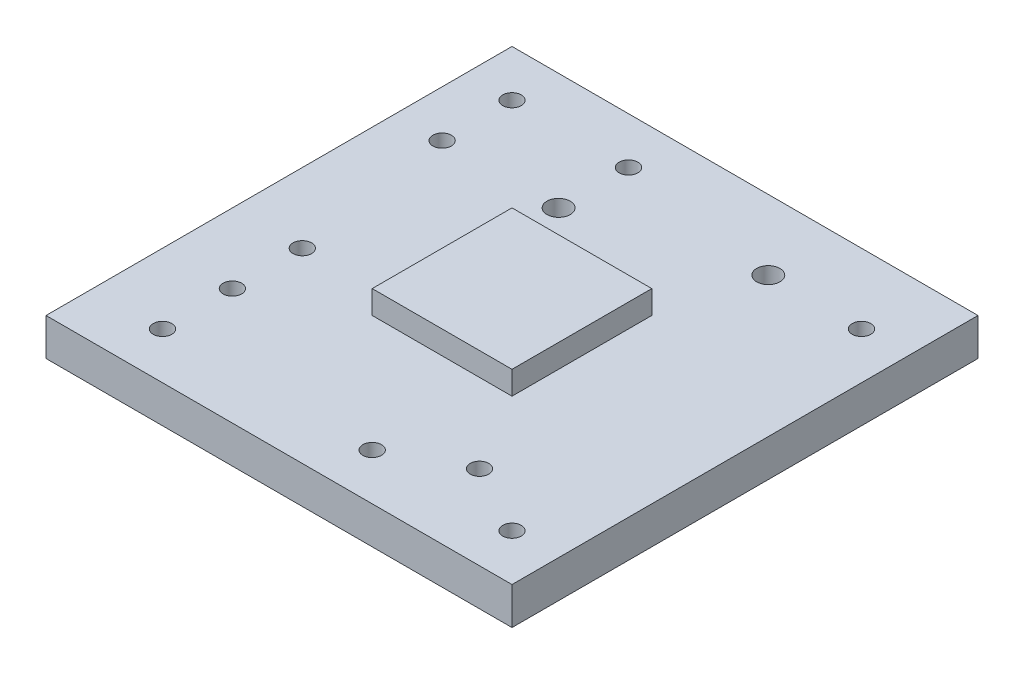
from build123d import *

# Parameters (mm, degrees)
SKETCH1_W           = 100
SKETCH1_H           = 100
BOSS_EXTRUDE1_DEPTH = 8
SKETCH2_W           = 30
SKETCH2_H           = 30
BOSS_EXTRUDE2_DEPTH = 5
SKETCH3_R           = 2
SKETCH3_R_2         = 2.5
CUT_EXTRUDE1_DEPTH  = 19
SKETCH4_R           = 2
SKETCH4_R_2         = 2.5
CUT_EXTRUDE2_DEPTH  = 19
SKETCH5_R           = 2
CUT_EXTRUDE3_DEPTH  = 19
SKETCH6_R           = 2
CUT_EXTRUDE4_DEPTH  = 19


with BuildPart() as part:
    # Sketch1 → Boss-Extrude1 (new body)
    with BuildSketch(Plane(origin=(0, 0, 0), x_dir=(1, 0, 0), z_dir=(0, 1, 0))):
        with Locations((50, 50)):
            Rectangle(SKETCH1_W, SKETCH1_H)
    extrude(amount=BOSS_EXTRUDE1_DEPTH)

    # Sketch2 → Boss-Extrude2 (add)
    with BuildSketch(Plane(origin=(0, 8, 0), x_dir=(1, 0, 0), z_dir=(0, 1, 0))):
        with Locations((50, 50)):
            Rectangle(SKETCH2_W, SKETCH2_H)
    extrude(amount=BOSS_EXTRUDE2_DEPTH)

    # Sketch3 → Cut-Extrude1 (cut)
    with BuildSketch(Plane(origin=(0, 8, 0), x_dir=(1, 0, 0), z_dir=(0, 1, 0))):
        with Locations((10, 90)):
            Circle(SKETCH3_R)
        with Locations((35, 90)):
            Circle(SKETCH3_R)
        with Locations((10, 75)):
            Circle(SKETCH3_R)
        with Locations((35, 75)):
            Circle(SKETCH3_R_2)
    extrude(amount=-CUT_EXTRUDE1_DEPTH, mode=Mode.SUBTRACT)

    # Sketch4 → Cut-Extrude2 (cut)
    with BuildSketch(Plane(origin=(0, 8, 0), x_dir=(1, 0, 0), z_dir=(0, 1, 0))):
        with Locations((90, 85)):
            Circle(SKETCH4_R)
        with Locations((70, 85)):
            Circle(SKETCH4_R_2)
    extrude(amount=-CUT_EXTRUDE2_DEPTH, mode=Mode.SUBTRACT)

    # Sketch5 → Cut-Extrude3 (cut)
    with BuildSketch(Plane(origin=(0, 8, 0), x_dir=(1, 0, 0), z_dir=(0, 1, 0))):
        with Locations((15, 10)):
            Circle(SKETCH5_R)
        with Locations((15, 25)):
            Circle(SKETCH5_R)
        with Locations((15, 40)):
            Circle(SKETCH5_R)
    extrude(amount=-CUT_EXTRUDE3_DEPTH, mode=Mode.SUBTRACT)

    # Sketch6 → Cut-Extrude4 (cut)
    with BuildSketch(Plane(origin=(0, 8, 0), x_dir=(1, 0, 0), z_dir=(0, 1, 0))):
        with Locations((90, 10)):
            Circle(SKETCH6_R)
        with Locations((60, 10)):
            Circle(SKETCH6_R)
        with Locations((75, 18.025911625)):
            Circle(SKETCH6_R)
    extrude(amount=-CUT_EXTRUDE4_DEPTH, mode=Mode.SUBTRACT)


solid = part.part
